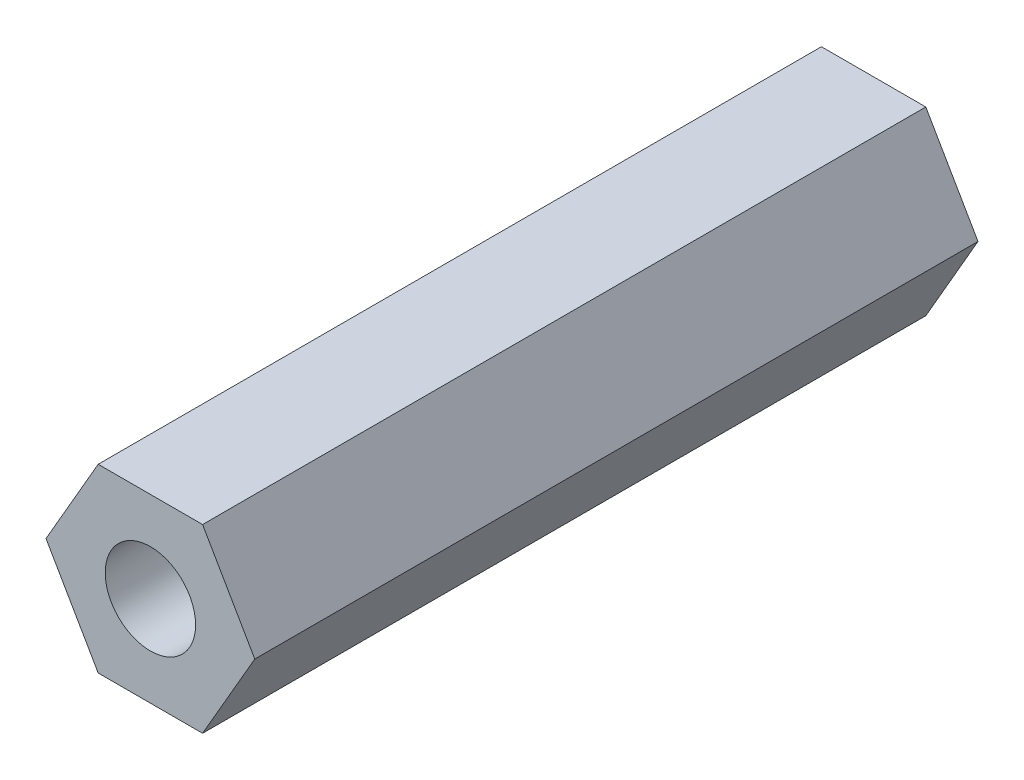
from build123d import *

# Parameters (mm, degrees)
EXTRUDE_1_DEPTH    = 20
HOLE_WIZARD_M3_1_D = 2.5


with BuildPart() as part:
    # 草图1 → 凸台-拉伸1 (new body)
    with BuildSketch(Plane.XY):
        Polygon((1.443375673, 2.5), (-1.443375673, 2.5), (-2.886751346, 0), (-1.443375673, -2.5), (1.443375673, -2.5), (2.886751346, 0), align=None)
    extrude(amount=EXTRUDE_1_DEPTH)

    # M3 螺纹孔1 (through all)
    with Locations(Plane.XY.offset(20)):
        with Locations((0, 0)):
            Hole(HOLE_WIZARD_M3_1_D / 2)


solid = part.part
